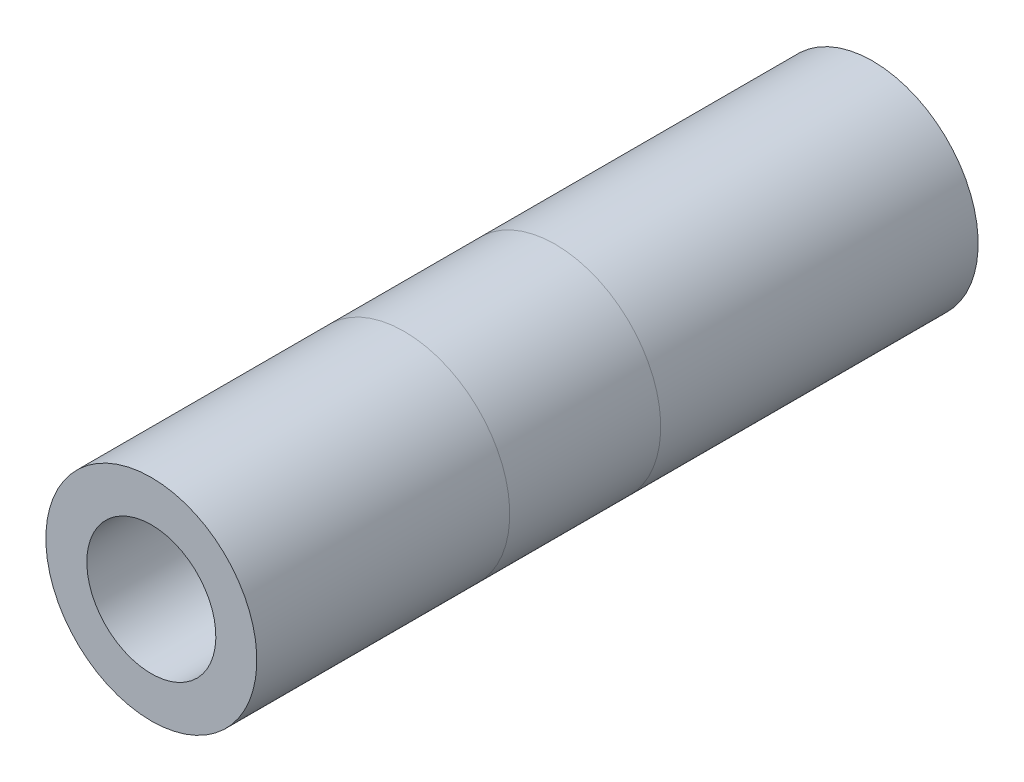
from build123d import *

# Parameters (mm, degrees)
SWEEP1_PROFILE_R     = 8.175
CUT_SWEEP1_PROFILE_R = 5


with BuildPart() as part:
    # Sweep1: sweep along a curve in space
    with BuildLine() as sweep1_path:
        Line((-46.03, 0, -24.6), (-46.03, 0, 0))
        Line((-46.03, 0, 0), (-46.03, 0, 11.700046958))
        Line((-46.03, 0, 31.301626468), (-46.03, 0, 11.700046958))
    # Sweep1 profile (on start of the path) → Sweep1 (sweep)
    with BuildSketch(Plane(origin=(-46.03, 0, -24.6), x_dir=(1, 0, 0), z_dir=(0, 0, 1))):
        Circle(SWEEP1_PROFILE_R)
    sweep(path=sweep1_path.line)

    # Cut-Sweep1: sweep along a curve in space
    with BuildLine() as cut_sweep1_path:
        Line((-46.03, 0, -24.6), (-46.03, 0, 0))
        Line((-46.03, 0, 0), (-46.03, 0, 11.700046958))
        Line((-46.03, 0, 31.301626468), (-46.03, 0, 11.700046958))
    # Cut-Sweep1 profile (on start of the path) → Cut-Sweep1 (sweep, cut)
    with BuildSketch(Plane(origin=(-46.03, 0, -24.6), x_dir=(1, 0, 0), z_dir=(0, 0, 1))):
        Circle(CUT_SWEEP1_PROFILE_R)
    sweep(path=cut_sweep1_path.line, mode=Mode.SUBTRACT)


solid = part.part
